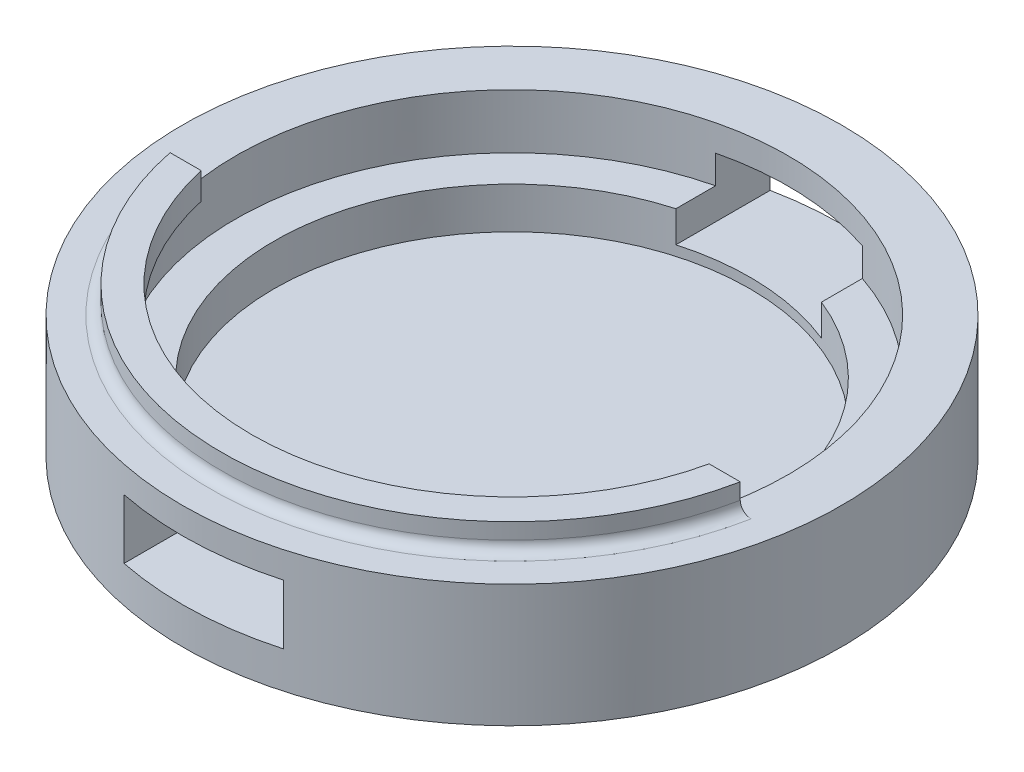
from build123d import *

# Parameters (mm, degrees)
CROQUIS1_R                 = 61.815
CROQUIS1_R_2               = 51.815
SALIENTE_EXTRUIR2_DEPTH    = 18
SALIENTE_EXTRUIR4_DEPTH    = 5
REDONDEO2_R                = 2
SALIENTE_EXTRUIR5_START    = 5
CROQUIS3_R                 = 61.815
SALIENTE_EXTRUIR5_DEPTH    = 5
CROQUIS4_R                 = 3.5
CORTAR_EXTRUIR1_DEPTH      = 5
CORTAR_EXTRUIR2_DEPTH      = 3
CORTAR_EXTRUIR3_DEPTH      = 3
CROQUIS10_W                = 7.196549014
CROQUIS10_H                = 7.75
CORTAR_EXTRUIR4_DEPTH      = 91.394626385
CORTAR_EXTRUIR4_DEPTH_BACK = 91.394626385
CROQUIS15_W                = 28.82841182
CROQUIS15_H                = 11.170270162


with BuildPart() as part:
    # Croquis1 → Saliente-Extruir2 (new body)
    with BuildSketch(Plane(origin=(0, 0, 0), x_dir=(1, 0, 0), z_dir=(0, 1, 0))):
        with Locations(Location((0, 0, 0), (0, 0, 270))):
            Circle(CROQUIS1_R)
        with Locations(Location((0, 0, 0), (0, 0, 270))):
            Circle(CROQUIS1_R_2, mode=Mode.SUBTRACT)
    extrude(amount=SALIENTE_EXTRUIR2_DEPTH)

    # Croquis2 → Saliente-Extruir4 (add)
    with BuildSketch(Plane(origin=(0, 18, 0), x_dir=(1, 0, 0), z_dir=(0, 1, 0))):
        with BuildLine():
            Line((47.648372829, -10.664156061), (53.47423337, -10.664156061))
            ThreePointArc((53.47423337, -10.664156061), (0, -54.527221266), (-53.47423337, -10.664156061))
            Line((-53.47423337, -10.664156061), (-47.648372829, -10.664156061))
            ThreePointArc((-47.648372829, -10.664156061), (0, -48.827161066), (47.648372829, -10.664156061))
        make_face()
    extrude(amount=SALIENTE_EXTRUIR4_DEPTH)

    # Redondeo2
    redondeo2_edges = [part.edges().sort_by_distance(p)[0] for p in [
        (0, 18, 54.527221266),
    ]]
    fillet(redondeo2_edges, radius=REDONDEO2_R)

    # Croquis3 → Saliente-Extruir5 (add)
    with BuildSketch(Plane.XZ.offset(SALIENTE_EXTRUIR5_START)):
        with Locations(Location((0, 0, 0), (0, 0, 270))):
            Circle(CROQUIS3_R)
    extrude(amount=-SALIENTE_EXTRUIR5_DEPTH)

    # Croquis4 → Cortar-Extruir1 (cut)
    with BuildSketch(Plane.XZ.offset(5)):
        with Locations(Location((0, 55.698306847, 0), (0, 0, 270))):
            Circle(CROQUIS4_R)
        with Locations(Location((55.698306847, 0, 0), (0, 0, 270))):
            Circle(CROQUIS4_R)
        with Locations(Location((0, -55.698306847, 0), (0, 0, 270))):
            Circle(CROQUIS4_R)
        with Locations(Location((-55.698306847, 0, 0), (0, 0, 270))):
            Circle(CROQUIS4_R)
    extrude(amount=-CORTAR_EXTRUIR1_DEPTH, mode=Mode.SUBTRACT)

    # Croquis6 → Cortar-Extruir2 (cut)
    with BuildSketch(Plane.XZ.offset(5)):
        with BuildLine():
            add(Edge.make_bspline(
                [(-10.111038217, 8.991376462), (-14.909869802, 15.405000934), (-3.102637577, 26.736623103), (26.676902991, 28.621830702), (9.311776718, 18.341245952), (8.643382771, 12.245828871), (8.991376671, 10.111038373)],
                knots=[0.006190105, 0.006190105, 0.006190105, 0.006190105, 0.153841075, 0.345957591, 0.455748295, 0.513420553, 0.513420553, 0.513420553, 0.513420553], degree=3))
            add(Edge.make_bspline(
                [(8.991376671, 10.111038373), (15.405001041, 14.909869691), (26.736623171, 3.102637446), (28.621830472, -26.676902898), (18.341246391, -9.311776982), (12.245828632, -8.643382623), (10.111038224, -8.991376461)],
                knots=[0.006190107, 0.006190107, 0.006190107, 0.006190107, 0.153841075, 0.345957591, 0.455748295, 0.51342055, 0.51342055, 0.51342055, 0.51342055], degree=3))
            add(Edge.make_bspline(
                [(10.111038224, -8.991376461), (14.909869853, -15.405000897), (3.102637543, -26.736623127), (-26.676902986, -28.621830697), (-9.311776717, -18.341245952), (-8.643382771, -12.245828869), (-8.991376672, -10.111038369)],
                knots=[0.006190105, 0.006190105, 0.006190105, 0.006190105, 0.153841075, 0.345957591, 0.455748295, 0.513420553, 0.513420553, 0.513420553, 0.513420553], degree=3))
            add(Edge.make_bspline(
                [(-8.991376672, -10.111038369), (-15.405001101, -14.909869705), (-26.736623131, -3.102637443), (-28.621830478, 26.676902897), (-18.341246388, 9.311776979), (-12.245828626, 8.643382623), (-10.111038217, 8.991376462)],
                knots=[0.006190107, 0.006190107, 0.006190107, 0.006190107, 0.153841075, 0.345957591, 0.455748295, 0.513420551, 0.513420551, 0.513420551, 0.513420551], degree=3))
        make_face()
    extrude(amount=-CORTAR_EXTRUIR2_DEPTH, mode=Mode.SUBTRACT)

    # Croquis7 → Cortar-Extruir3 (cut)
    with BuildSketch(Plane.XZ.offset(5)):
        with BuildLine():
            add(Edge.make_bspline(
                [(11.855904693, -9.841761323), (12.499498417, -9.838917037), (13.132342196, -9.904435011), (14.062954266, -10.121336056), (14.372054579, -10.214232699), (14.973404004, -10.43847573), (15.264163072, -10.568916187), (15.827131505, -10.864067281), (16.099059433, -11.029297865), (16.628249894, -11.38685304), (16.886377057, -11.579637308), (17.634396808, -12.179591566), (18.101927035, -12.609809135), (19.45489458, -13.948648769), (20.289106236, -14.907013904), (21.542348471, -16.342692563), (21.959663676, -16.821671814), (22.608990328, -17.517462761), (22.829540817, -17.745632988), (23.287711919, -18.184436122), (23.524159319, -18.394678709), (24.030284796, -18.773821126), (24.303180982, -18.944533116), (24.744802809, -19.118637227), (24.899914034, -19.163370668), (25.211403739, -19.215570942), (25.368252072, -19.223756507), (25.684434599, -19.199770666), (25.842571837, -19.166896669), (26.140571779, -19.063063391), (26.284872543, -18.990611138), (26.681509767, -18.726061479), (26.900211947, -18.485228763), (27.243210519, -17.955277659), (27.37353389, -17.660903008), (27.577314135, -17.064544839), (27.652808697, -16.758703477), (27.772493382, -16.137933496), (27.81606989, -15.82387574), (27.88105835, -15.198854753), (27.902588289, -14.886427724), (27.943636298, -13.949325848), (27.940043228, -13.324826932), (27.893481389, -12.076128845), (27.850050552, -11.451933191), (27.732449282, -10.203775885), (27.658017965, -9.579279954), (27.48429565, -8.340279217), (27.384856004, -7.724465402), (27.052815486, -5.886907214), (26.786950332, -4.67491207), (26.170568519, -2.275731785), (25.819985913, -1.088565973), (25.022943554, 1.257665593), (24.576847167, 2.416837842), (23.813267366, 4.127918763), (23.542832625, 4.693616648), (22.962850621, 5.813549163), (22.655191935, 6.364053341), (21.998793099, 7.437648803), (21.649834601, 7.961386641), (20.898278428, 8.975116991), (20.497267705, 9.462621655), (19.639805692, 10.375985069), (19.182418037, 10.803570186), (18.437957306, 11.385672362), (18.178582597, 11.570551499), (17.646252573, 11.910388848), (17.372911944, 12.065844707), (16.810317183, 12.344681974), (16.521068392, 12.468074142), (15.924688161, 12.67881511), (15.61731256, 12.765778829), (14.694956289, 12.96108238), (14.070767644, 13.007693179), (13.120263712, 12.949572632), (12.805329849, 12.908896381), (12.187179087, 12.789824279), (11.882569134, 12.711343319), (11.281456427, 12.519986019), (10.983959289, 12.406607508), (10.40324469, 12.151553417), (10.119588267, 12.00988182), (9.84176147, 11.855904754)],
                knots=[0, 0, 0, 0, 0.03125, 0.03125, 0.046875, 0.046875, 0.0625, 0.0625, 0.078125, 0.078125, 0.09375, 0.09375, 0.125, 0.125, 0.1875, 0.1875, 0.21875, 0.21875, 0.234375, 0.234375, 0.25, 0.25, 0.265625, 0.265625, 0.2734375, 0.2734375, 0.28125, 0.28125, 0.2890625, 0.2890625, 0.296875, 0.296875, 0.3125, 0.3125, 0.328125, 0.328125, 0.34375, 0.34375, 0.359375, 0.359375, 0.375, 0.375, 0.40625, 0.40625, 0.4375, 0.4375, 0.46875, 0.46875, 0.5, 0.5, 0.5625, 0.5625, 0.625, 0.625, 0.6875, 0.6875, 0.71875, 0.71875, 0.75, 0.75, 0.78125, 0.78125, 0.8125, 0.8125, 0.84375, 0.84375, 0.859375, 0.859375, 0.875, 0.875, 0.890625, 0.890625, 0.90625, 0.90625, 0.9375, 0.9375, 0.953125, 0.953125, 0.96875, 0.96875, 0.984375, 0.984375, 1, 1, 1, 1], degree=3))
            add(Edge.make_bspline(
                [(9.84176147, 11.855904754), (9.838917146, 12.499498481), (9.904435083, 13.132342269), (10.121336101, 14.062954355), (10.21423274, 14.372054677), (10.438475768, 14.973404102), (10.568916228, 15.264163169), (10.864067335, 15.827131598), (11.029297928, 16.099059525), (11.386853123, 16.628249983), (11.579637401, 16.886377143), (12.179591678, 17.634396876), (12.609809257, 18.101927093), (13.948648914, 19.454894617), (14.907014053, 20.289106272), (16.342692702, 21.54234852), (16.821671947, 21.959663731), (17.517462879, 22.608990399), (17.745633109, 22.829540901), (18.184436213, 23.287711999), (18.394678787, 23.524159398), (18.77382118, 24.030284879), (18.94453317, 24.303181083), (19.11863727, 24.744802936), (19.163370705, 24.899914165), (19.215570968, 25.211403884), (19.223756527, 25.36825223), (19.199770666, 25.684434794), (19.166896663, 25.842572011), (19.06306337, 26.140571951), (18.990611103, 26.284872726), (18.726061436, 26.681509928), (18.485228712, 26.900212108), (17.955277591, 27.243210681), (17.660902935, 27.373534051), (17.064544766, 27.577314292), (16.758703395, 27.652808858), (16.13793338, 27.772493546), (15.823875641, 27.816070051), (15.198854665, 27.881058509), (14.886427638, 27.902588447), (13.94932576, 27.943636456), (13.324826833, 27.940043385), (12.076128711, 27.893481541), (11.451933033, 27.8500507), (10.20377567, 27.732449417), (9.579279747, 27.658018095), (8.340279049, 27.484295778), (7.724465251, 27.384856131), (5.886907105, 27.05281561), (4.674911978, 26.786950453), (2.275731706, 26.170568627), (1.08856589, 25.819986011), (-1.257665705, 25.022943622), (-2.41683798, 24.576847214), (-4.127918958, 23.813267364), (-4.693616866, 23.542832603), (-5.813549433, 22.96285055), (-6.364053557, 22.655191881), (-7.437649002, 21.998793032), (-7.961386838, 21.649834523), (-8.975117197, 20.898278312), (-9.462621809, 20.497267614), (-10.375985192, 19.639805597), (-10.803570306, 19.18241793), (-11.385672494, 18.437957147), (-11.570551629, 18.178582424), (-11.910388944, 17.646252421), (-12.065844792, 17.372911796), (-12.344682044, 16.810317029), (-12.468074209, 16.521068225), (-12.678815173, 15.924687949), (-12.765778873, 15.617312375), (-12.961082387, 14.694956157), (-13.007693182, 14.070767505), (-12.949572606, 13.120263496), (-12.908896351, 12.805329684), (-12.789824239, 12.18717894), (-12.711343275, 11.882568988), (-12.51998596, 11.281456269), (-12.406607438, 10.983959121), (-12.151553341, 10.403244536), (-12.009881742, 10.119588117), (-11.855904672, 9.841761323)],
                knots=[0, 0, 0, 0, 0.03125, 0.03125, 0.046875, 0.046875, 0.0625, 0.0625, 0.078125, 0.078125, 0.09375, 0.09375, 0.125, 0.125, 0.1875, 0.1875, 0.21875, 0.21875, 0.234375, 0.234375, 0.25, 0.25, 0.265625, 0.265625, 0.2734375, 0.2734375, 0.28125, 0.28125, 0.2890625, 0.2890625, 0.296875, 0.296875, 0.3125, 0.3125, 0.328125, 0.328125, 0.34375, 0.34375, 0.359375, 0.359375, 0.375, 0.375, 0.40625, 0.40625, 0.4375, 0.4375, 0.46875, 0.46875, 0.5, 0.5, 0.5625, 0.5625, 0.625, 0.625, 0.6875, 0.6875, 0.71875, 0.71875, 0.75, 0.75, 0.78125, 0.78125, 0.8125, 0.8125, 0.84375, 0.84375, 0.859375, 0.859375, 0.875, 0.875, 0.890625, 0.890625, 0.90625, 0.90625, 0.9375, 0.9375, 0.953125, 0.953125, 0.96875, 0.96875, 0.984375, 0.984375, 1, 1, 1, 1], degree=3))
            add(Edge.make_bspline(
                [(-11.855904672, 9.841761323), (-12.499498397, 9.838917035), (-13.132342178, 9.904435008), (-14.062954249, 10.121336052), (-14.372054563, 10.214232694), (-14.97340399, 10.438475724), (-15.264163059, 10.568916181), (-15.827131493, 10.864067274), (-16.099059422, 11.029297858), (-16.628249885, 11.386853033), (-16.886377049, 11.579637302), (-17.634396801, 12.17959156), (-18.10192703, 12.609809129), (-19.454894577, 13.948648764), (-20.289106236, 14.907013901), (-21.542348474, 16.342692561), (-21.95966368, 16.821671813), (-22.608990334, 17.517462759), (-22.829540824, 17.745632987), (-23.287711927, 18.184436121), (-23.524159327, 18.394678708), (-24.030284806, 18.773821124), (-24.303180994, 18.944533114), (-24.744802822, 19.118637225), (-24.899914047, 19.163370666), (-25.211403753, 19.21557094), (-25.368252087, 19.223756505), (-25.684434615, 19.199770663), (-25.842571853, 19.166896667), (-26.140571795, 19.063063389), (-26.284872559, 18.990611136), (-26.681509785, 18.726061477), (-26.900211966, 18.485228761), (-27.243210541, 17.955277658), (-27.373533914, 17.660903006), (-27.577314161, 17.064544837), (-27.652808725, 16.758703475), (-27.772493412, 16.137933493), (-27.816069922, 15.823875737), (-27.881058385, 15.198854749), (-27.902588324, 14.88642772), (-27.943636337, 13.949325842), (-27.940043269, 13.324826924), (-27.893481434, 12.076128834), (-27.850050598, 11.451933179), (-27.732449331, 10.203775871), (-27.658018015, 9.579279938), (-27.484295703, 8.340279198), (-27.384856058, 7.724465382), (-27.052815543, 5.88690719), (-26.786950391, 4.674912044), (-26.17056858, 2.275731754), (-25.819985974, 1.088565939), (-25.022943615, -1.257665632), (-24.576847227, -2.416837884), (-23.813267423, -4.127918809), (-23.542832681, -4.693616695), (-22.962850674, -5.813549213), (-22.655191987, -6.364053391), (-21.998793148, -7.437648853), (-21.649834648, -7.961386691), (-20.898278469, -8.975117041), (-20.497267744, -9.462621703), (-19.639805726, -10.375985114), (-19.182418068, -10.803570229), (-18.437957331, -11.385672402), (-18.17858262, -11.570551537), (-17.646252593, -11.910388883), (-17.372911962, -12.06584474), (-16.810317199, -12.344682002), (-16.521068406, -12.468074168), (-15.92468817, -12.678815132), (-15.617312569, -12.765778849), (-14.694956297, -12.961082393), (-14.07076765, -13.007693188), (-13.120263714, -12.949572635), (-12.805329853, -12.908896382), (-12.18717909, -12.789824277), (-11.882569137, -12.711343316), (-11.281456429, -12.519986014), (-10.98395929, -12.406607502), (-10.403244691, -12.15155341), (-10.119588267, -12.009881813), (-9.84176147, -11.855904747)],
                knots=[0, 0, 0, 0, 0.03125, 0.03125, 0.046875, 0.046875, 0.0625, 0.0625, 0.078125, 0.078125, 0.09375, 0.09375, 0.125, 0.125, 0.1875, 0.1875, 0.21875, 0.21875, 0.234375, 0.234375, 0.25, 0.25, 0.265625, 0.265625, 0.2734375, 0.2734375, 0.28125, 0.28125, 0.2890625, 0.2890625, 0.296875, 0.296875, 0.3125, 0.3125, 0.328125, 0.328125, 0.34375, 0.34375, 0.359375, 0.359375, 0.375, 0.375, 0.40625, 0.40625, 0.4375, 0.4375, 0.46875, 0.46875, 0.5, 0.5, 0.5625, 0.5625, 0.625, 0.625, 0.6875, 0.6875, 0.71875, 0.71875, 0.75, 0.75, 0.78125, 0.78125, 0.8125, 0.8125, 0.84375, 0.84375, 0.859375, 0.859375, 0.875, 0.875, 0.890625, 0.890625, 0.90625, 0.90625, 0.9375, 0.9375, 0.953125, 0.953125, 0.96875, 0.96875, 0.984375, 0.984375, 1, 1, 1, 1], degree=3))
            add(Edge.make_bspline(
                [(-9.84176147, -11.855904747), (-9.838917146, -12.499498474), (-9.904435082, -13.132342262), (-10.121336099, -14.062954348), (-10.214232738, -14.372054669), (-10.438475765, -14.973404095), (-10.568916225, -15.264163162), (-10.864067331, -15.827131592), (-11.029297924, -16.099059518), (-11.386853118, -16.628249977), (-11.579637396, -16.886377137), (-12.179591672, -17.63439687), (-12.609809251, -18.101927088), (-13.948648907, -19.454894612), (-14.907014046, -20.289106266), (-16.342692694, -21.542348514), (-16.821671939, -21.959663726), (-17.517462872, -22.608990393), (-17.745633101, -22.829540895), (-18.184436206, -23.287711993), (-18.394678779, -23.524159392), (-18.773821172, -24.030284873), (-18.944533162, -24.303181077), (-19.118637261, -24.744802931), (-19.163370695, -24.899914159), (-19.215570957, -25.211403879), (-19.223756516, -25.368252225), (-19.199770652, -25.684434789), (-19.166896649, -25.842572005), (-19.063063355, -26.140571945), (-18.990611087, -26.28487272), (-18.726061418, -26.68150992), (-18.485228692, -26.900212099), (-17.955277569, -27.243210668), (-17.660902913, -27.373534037), (-17.064544743, -27.577314276), (-16.758703371, -27.65280884), (-16.137933356, -27.772493528), (-15.823875617, -27.816070031), (-15.198854641, -27.881058488), (-14.886427614, -27.902588426), (-13.949325737, -27.943636433), (-13.32482681, -27.940043361), (-12.076128688, -27.893481515), (-11.45193301, -27.850050673), (-10.203775647, -27.732449389), (-9.579279724, -27.658018067), (-8.340279027, -27.484295749), (-7.72446523, -27.384856102), (-5.886907084, -27.052815579), (-4.674911957, -26.786950422), (-2.275731686, -26.170568597), (-1.08856587, -25.819985981), (1.257665725, -25.022943593), (2.416838, -24.576847186), (4.127918978, -23.813267339), (4.693616886, -23.542832579), (5.813549453, -22.962850528), (6.364053579, -22.655191859), (7.437649024, -21.998793012), (7.961386861, -21.649834505), (8.975117221, -20.898278296), (9.462621835, -20.4972676), (10.37598522, -19.639805585), (10.803570336, -19.182417919), (11.385672525, -18.437957138), (11.570551661, -18.178582415), (11.910388977, -17.646252414), (12.065844826, -17.372911789), (12.34468208, -16.810317022), (12.468074245, -16.521068219), (12.67881521, -15.924687943), (12.76577891, -15.617312369), (12.961082424, -14.694956151), (13.007693219, -14.0707675), (12.94957264, -13.12026349), (12.908896385, -12.805329679), (12.789824272, -12.187178935), (12.711343306, -11.882568984), (12.519985988, -11.281456266), (12.406607465, -10.983959118), (12.151553365, -10.403244534), (12.009881764, -10.119588116), (11.855904693, -9.841761323)],
                knots=[0, 0, 0, 0, 0.03125, 0.03125, 0.046875, 0.046875, 0.0625, 0.0625, 0.078125, 0.078125, 0.09375, 0.09375, 0.125, 0.125, 0.1875, 0.1875, 0.21875, 0.21875, 0.234375, 0.234375, 0.25, 0.25, 0.265625, 0.265625, 0.2734375, 0.2734375, 0.28125, 0.28125, 0.2890625, 0.2890625, 0.296875, 0.296875, 0.3125, 0.3125, 0.328125, 0.328125, 0.34375, 0.34375, 0.359375, 0.359375, 0.375, 0.375, 0.40625, 0.40625, 0.4375, 0.4375, 0.46875, 0.46875, 0.5, 0.5, 0.5625, 0.5625, 0.625, 0.625, 0.6875, 0.6875, 0.71875, 0.71875, 0.75, 0.75, 0.78125, 0.78125, 0.8125, 0.8125, 0.84375, 0.84375, 0.859375, 0.859375, 0.875, 0.875, 0.890625, 0.890625, 0.90625, 0.90625, 0.9375, 0.9375, 0.953125, 0.953125, 0.96875, 0.96875, 0.984375, 0.984375, 1, 1, 1, 1], degree=3))
        make_face()
    extrude(amount=-CORTAR_EXTRUIR3_DEPTH, mode=Mode.SUBTRACT)

    # Barrer2: sweep along a curve in space
    with BuildLine() as barrer2_path:
        ThreePointArc((0, 0, 51.815), (36.638737867, 0, 36.638737867), (51.815, 0, 0))
        ThreePointArc((51.815, 0, 0), (36.638737867, 0, -36.638737867), (0, 0, -51.815))
        ThreePointArc((0, 0, -51.815), (-36.638737867, 0, -36.638737867), (-51.815, 0, 0))
        ThreePointArc((-51.815, 0, 0), (-36.638737867, 0, 36.638737867), (0, 0, 51.815))
    # Croquis10 → Barrer2 (sweep)
    with BuildSketch(Plane.XY):
        with Locations((48.216725493, 3.875)):
            Rectangle(CROQUIS10_W, CROQUIS10_H)
    sweep(path=barrer2_path.line)

    # Croquis15 → Cortar-Extruir4 (cut, two sides: drawn at the far end of the back side and taken through both)
    with BuildSketch(Plane.XY.offset(-CORTAR_EXTRUIR4_DEPTH_BACK)):
        with Locations((2.233186831, 7.470204612)):
            Rectangle(CROQUIS15_W, CROQUIS15_H)
    extrude(amount=CORTAR_EXTRUIR4_DEPTH + CORTAR_EXTRUIR4_DEPTH_BACK, mode=Mode.SUBTRACT)


solid = part.part
